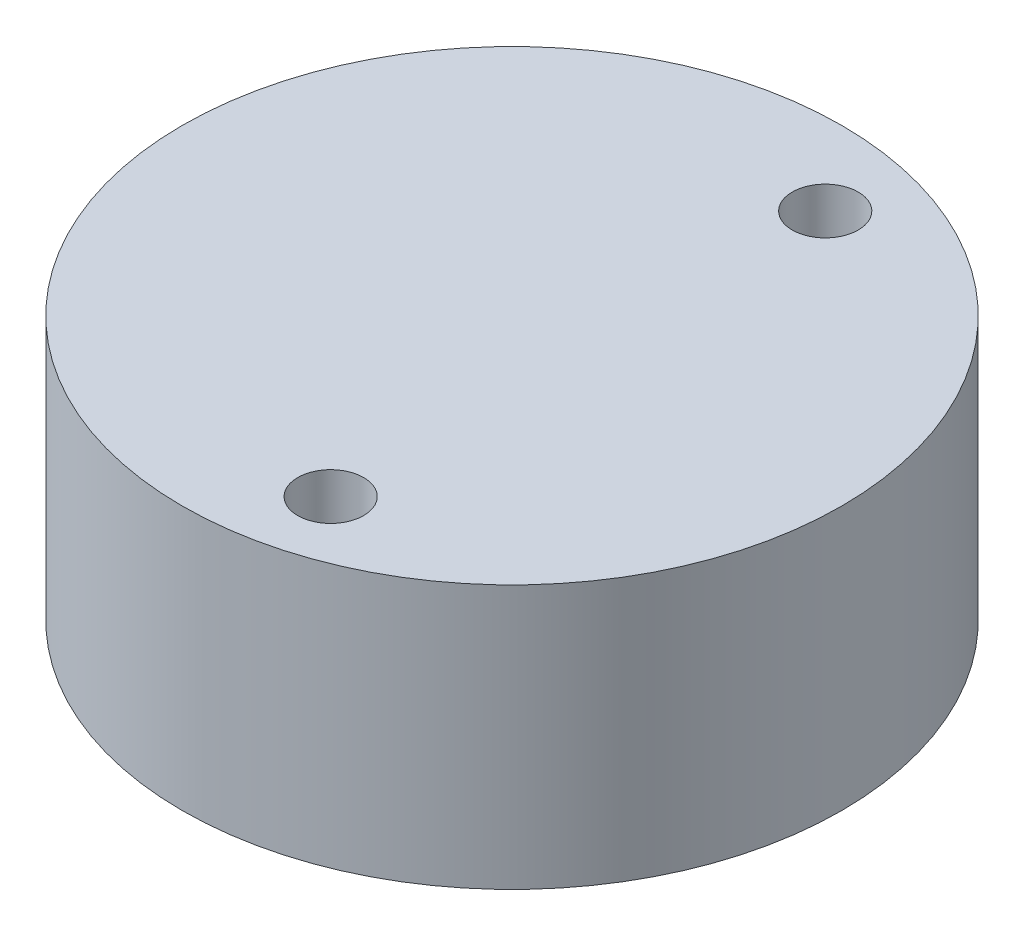
from build123d import *

# Parameters (mm, degrees)
SKETCH1_R           = 5
SKETCH1_R_2         = 3
BOSS_EXTRUDE1_DEPTH = 2
SKETCH2_R           = 5
BOSS_EXTRUDE2_DEPTH = 2
SKETCH3_R           = 0.5
CUT_EXTRUDE1_DEPTH  = 5
BOSS_EXTRUDE3_DEPTH = 4


with BuildPart() as part:
    # Sketch1 → Boss-Extrude1 (new body)
    with BuildSketch(Plane(origin=(0, 0, 0), x_dir=(1, 0, 0), z_dir=(0, 1, 0))):
        with Locations((-1, 0)):
            Circle(SKETCH1_R)
        Circle(SKETCH1_R_2, mode=Mode.SUBTRACT)
    extrude(amount=BOSS_EXTRUDE1_DEPTH)

    # Sketch2 → Boss-Extrude2 (add)
    with BuildSketch(Plane(origin=(0, 2, 0), x_dir=(1, 0, 0), z_dir=(0, 1, 0))):
        with Locations((-1, 0)):
            Circle(SKETCH2_R)
    extrude(amount=BOSS_EXTRUDE2_DEPTH)

    # Sketch3 → Cut-Extrude1 (cut, through all)
    with BuildSketch(Plane.XZ):
        with Locations((0, 3.75)):
            Circle(SKETCH3_R)
        with Locations((0, -3.75)):
            Circle(SKETCH3_R)
    extrude(amount=-CUT_EXTRUDE1_DEPTH, mode=Mode.SUBTRACT)

    # Sketch4 → Boss-Extrude3 (add)
    with BuildSketch(Plane.XZ):
        with BuildLine():
            ThreePointArc((-2, 2.236067977), (-3, 0), (-2, -2.236067977))
            Line((-2, -2.236067977), (-2, 2.236067977))
        make_face()
    extrude(amount=-BOSS_EXTRUDE3_DEPTH)


solid = part.part
